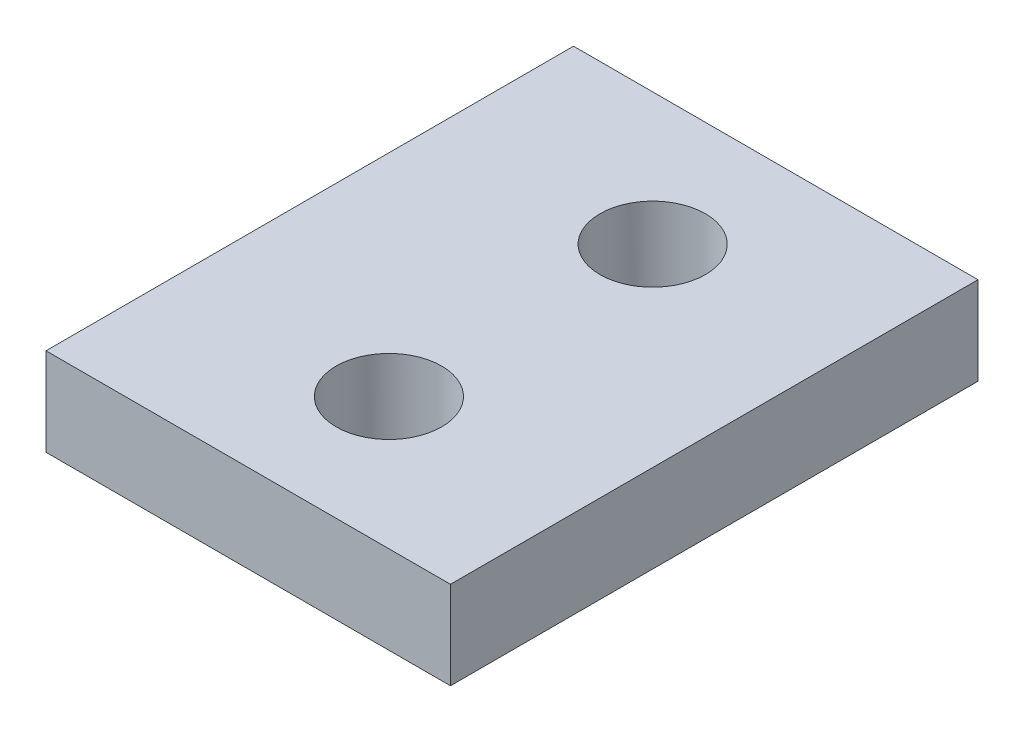
from build123d import *

# Parameters (mm, degrees)
SKIZZE3_W                            = 23
SKIZZE3_H                            = 5
AUFSATZ_LINEAR_AUSTRAGEN1_DEPTH      = 15
AUFSATZ_LINEAR_AUSTRAGEN1_DEPTH_BACK = 15
SKIZZE5_R                            = 3
SCHNITT_LINEAR_AUSTRAGEN1_DEPTH      = 16


with BuildPart() as part:
    # Skizze3 → Aufsatz-Linear austragen1 (new body, two sides)
    with BuildSketch(Plane.XY) as aufsatz_linear_austragen1_sk:
        with Locations((-53.5, -13.5)):
            Rectangle(SKIZZE3_W, SKIZZE3_H)
    extrude(amount=AUFSATZ_LINEAR_AUSTRAGEN1_DEPTH)
    extrude(aufsatz_linear_austragen1_sk.sketch, amount=-AUFSATZ_LINEAR_AUSTRAGEN1_DEPTH_BACK)

    # Skizze5 → Schnitt-Linear austragen1 (cut)
    with BuildSketch(Plane(origin=(0, 0, 0), x_dir=(1, 0, 0), z_dir=(0, 1, 0))):
        with Locations((-53, 7.5)):
            Circle(SKIZZE5_R)
        with Locations((-53, -7.5)):
            Circle(SKIZZE5_R)
    extrude(amount=-SCHNITT_LINEAR_AUSTRAGEN1_DEPTH, mode=Mode.SUBTRACT)


solid = part.part
